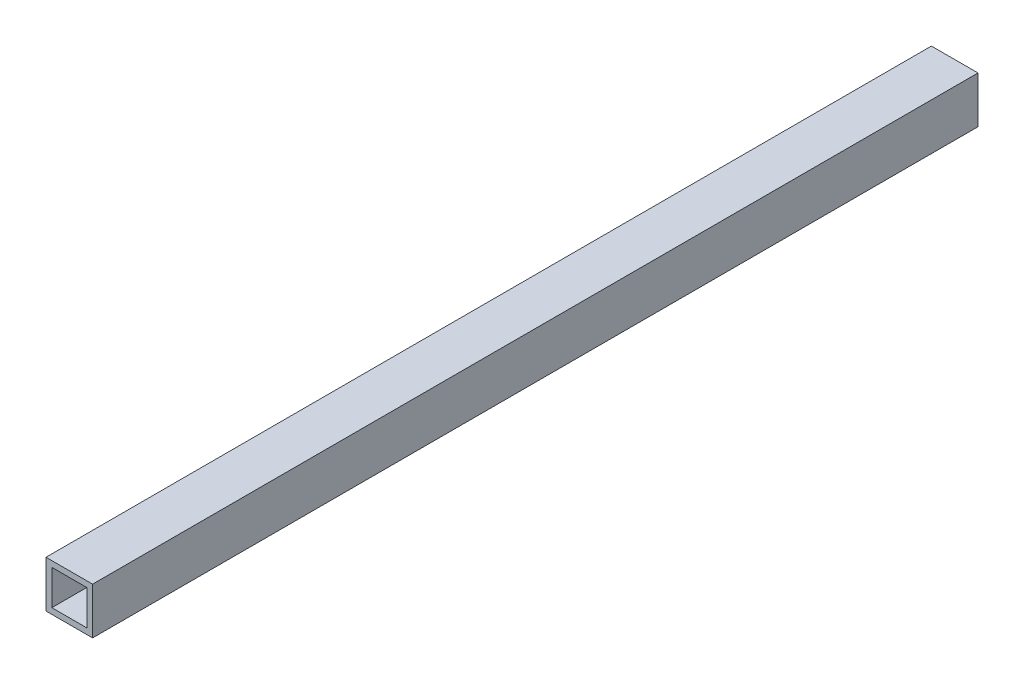
from build123d import *

# Parameters (mm, degrees)
SKETCH1_W           = 25.4
SKETCH1_H           = 25.4
SKETCH1_W_2         = 19.05
SKETCH1_H_2         = 19.05
BOSS_EXTRUDE1_DEPTH = 482.6


with BuildPart() as part:
    # Sketch1 → Boss-Extrude1 (new body)
    with BuildSketch(Plane.XY):
        Rectangle(SKETCH1_W, SKETCH1_H)
        Rectangle(SKETCH1_W_2, SKETCH1_H_2, mode=Mode.SUBTRACT)
    extrude(amount=BOSS_EXTRUDE1_DEPTH)


solid = part.part
